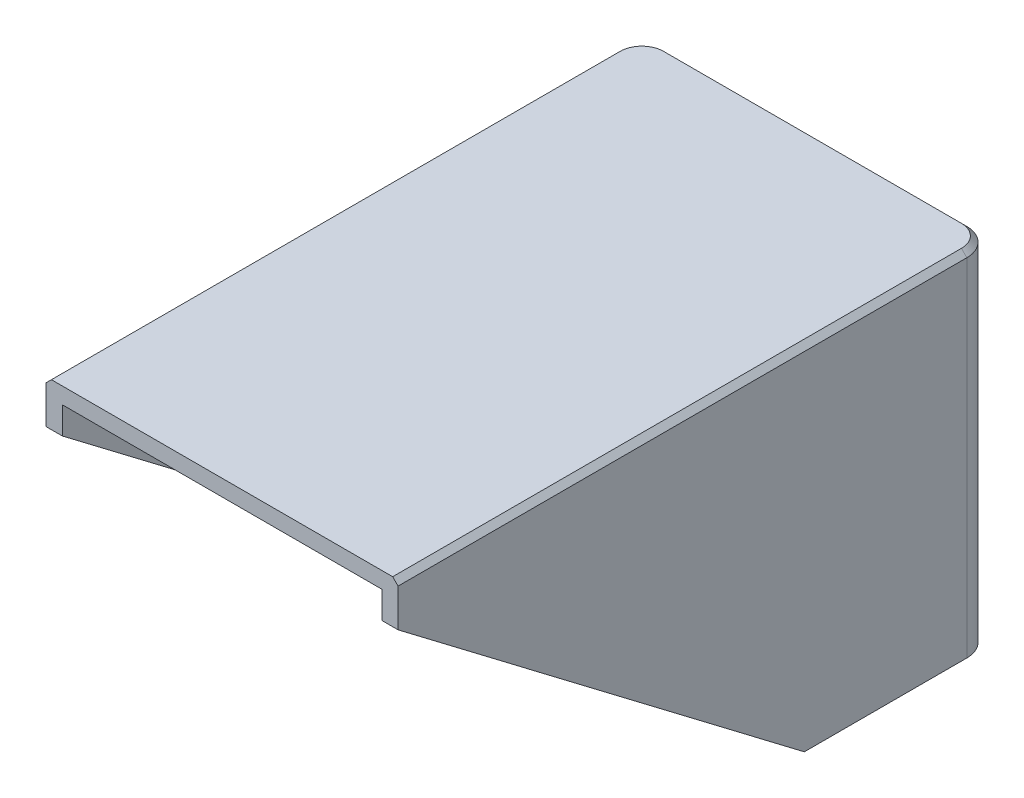
from build123d import *

# Parameters (mm, degrees)
ESQUISSE1_W             = 65
ESQUISSE1_H             = 125
BOSS_EXTRU_1_DEPTH      = 80
COQUE1_T                = -3
ESQUISSE2_OUTSIDE_W     = 159.404
ESQUISSE2_OUTSIDE_H     = 114.404
ENL_V_MAT_EXTRU_1_DEPTH = 66
CONG_2_R                = 5
CONG_3_R                = 2
CHANFREIN1_SIZE         = 1
ESQUISSE3_R             = 15.24
ENL_V_MAT_EXTRU_2_DEPTH = 0.1


with BuildPart() as part:
    # Esquisse1 → Boss.-Extru.1 (new body)
    with BuildSketch(Plane(origin=(0, 0, 0), x_dir=(1, 0, 0), z_dir=(0, 1, 0))):
        Rectangle(ESQUISSE1_W, ESQUISSE1_H)
    extrude(amount=BOSS_EXTRU_1_DEPTH)

    # Coque1
    coque1_openings = [part.faces().sort_by_distance(p)[0] for p in [
        (0, 0, 0),
    ]]
    offset(amount=COQUE1_T, openings=coque1_openings, kind=Kind.INTERSECTION)

    # Esquisse2 outside → Enlèv. mat.-Extru.1 (cut, through all)
    with BuildSketch(Plane(origin=(32.5, 0, 0), x_dir=(0, 0, -1), z_dir=(1, 0, 0))):
        with Locations((0, 40)):
            Rectangle(ESQUISSE2_OUTSIDE_W, ESQUISSE2_OUTSIDE_H)
        Polygon((-47.5, 80), (-47.5, 72), (27.5, 15), (62.5, 15), (62.5, 80), align=None, mode=Mode.SUBTRACT)
    extrude(amount=-ENL_V_MAT_EXTRU_1_DEPTH, mode=Mode.SUBTRACT)

    # Congé2
    cong_2_edges = [part.edges().sort_by_distance(p)[0] for p in [
        (-32.5, 47.5, -62.5),
        (32.5, 47.5, -62.5),
    ]]
    fillet(cong_2_edges, radius=CONG_2_R)

    # Congé3
    cong_3_edges = [part.edges().sort_by_distance(p)[0] for p in [
        (29.5, 46, -59.5),
        (-29.5, 46, -59.5),
    ]]
    fillet(cong_3_edges, radius=CONG_3_R)

    # Chanfrein1
    chanfrein1_edges = [part.edges().sort_by_distance(p)[0] for p in [
        (32.5, 80, -5),
        (-32.5, 80, -5),
        (0, 80, -62.5),
        (31.035533906, 80, -61.035533906),
        (-31.035533906, 80, -61.035533906),
    ]]
    chamfer(chanfrein1_edges, length=CHANFREIN1_SIZE)

    # Esquisse3 → Enlèv. mat.-Extru.2 (cut)
    with BuildSketch(Plane(origin=(0, 0, -62.5), x_dir=(-1, 0, 0), z_dir=(0, 0, -1))):
        with Locations((0, 55)):
            Circle(ESQUISSE3_R)
    extrude(amount=-ENL_V_MAT_EXTRU_2_DEPTH, mode=Mode.SUBTRACT)


solid = part.part
